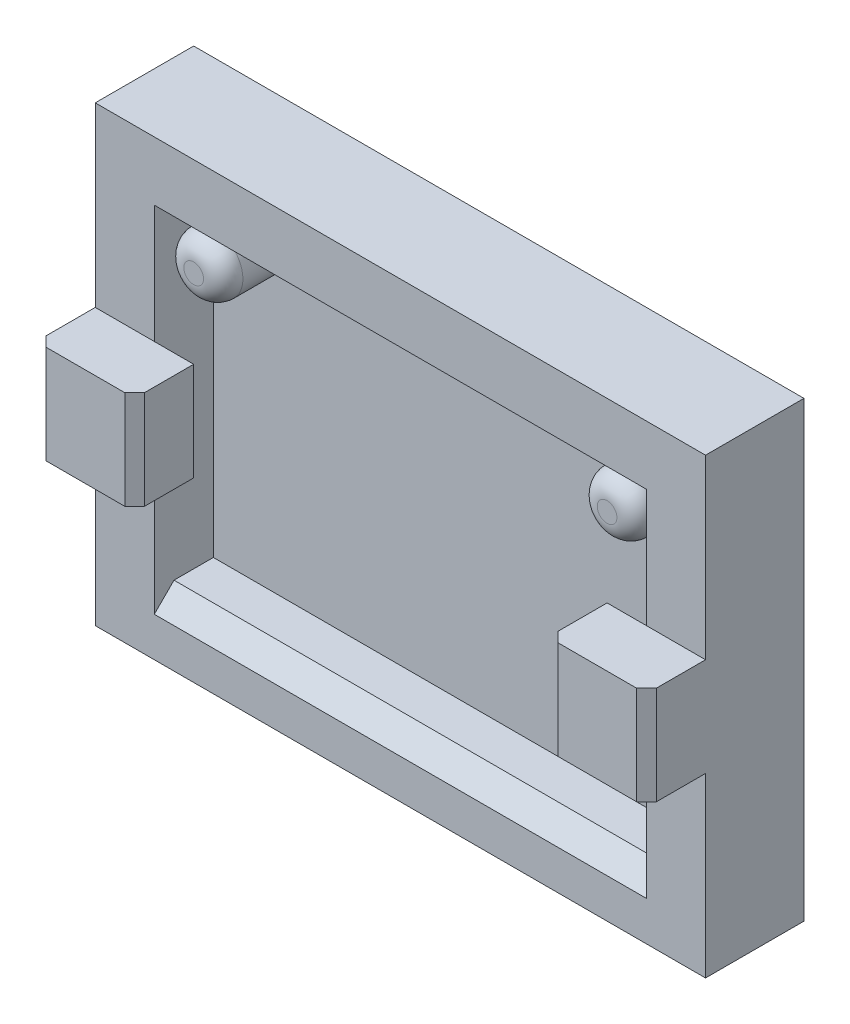
from build123d import *

# Parameters (mm, degrees)
ESQUISSE1_W             = 31
ESQUISSE1_H             = 23
BOSS_EXTRU_1_DEPTH      = 5
ESQUISSE2_W             = 25
ESQUISSE2_H             = 17
ENL_V_MAT_EXTRU_1_DEPTH = 3
ESQUISSE3_R             = 1.5
BOSS_EXTRU_2_DEPTH      = 3
CONG_1_R                = 1
ESQUISSE4_W             = 5
ESQUISSE4_H             = 5
BOSS_EXTRU_3_DEPTH      = 3
CHANFREIN1_SIZE         = 0.5
CHANFREIN2_SIZE         = 1


with BuildPart() as part:
    # Esquisse1 → Boss.-Extru.1 (new body)
    with BuildSketch(Plane.XY):
        with Locations((-15.5, 11.5)):
            Rectangle(ESQUISSE1_W, ESQUISSE1_H)
    extrude(amount=BOSS_EXTRU_1_DEPTH)

    # Esquisse2 → Enlèv. mat.-Extru.1 (cut)
    with BuildSketch(Plane.XY.offset(5)):
        with Locations((-15.5, 11.5)):
            Rectangle(ESQUISSE2_W, ESQUISSE2_H)
    extrude(amount=-ENL_V_MAT_EXTRU_1_DEPTH, mode=Mode.SUBTRACT)

    # Esquisse3 → Boss.-Extru.2 (add)
    with BuildSketch(Plane.XY.offset(2)):
        with Locations((-26, 18)):
            Circle(ESQUISSE3_R)
        with Locations((-5, 18)):
            Circle(ESQUISSE3_R)
    extrude(amount=BOSS_EXTRU_2_DEPTH)

    # Congé1
    cong_1_edges = [part.edges().sort_by_distance(p)[0] for p in [
        (-27.5, 18, 5),
        (-6.5, 18, 5),
    ]]
    fillet(cong_1_edges, radius=CONG_1_R)

    # Esquisse4 → Boss.-Extru.3 (add)
    with BuildSketch(Plane.XY.offset(5)):
        with Locations((-28.5, 11.5)):
            Rectangle(ESQUISSE4_W, ESQUISSE4_H)
        with Locations((-2.5, 11.5)):
            Rectangle(ESQUISSE4_W, ESQUISSE4_H)
    extrude(amount=BOSS_EXTRU_3_DEPTH)

    # Chanfrein1
    chanfrein1_edges = [part.edges().sort_by_distance(p)[0] for p in [
        (0, 11.5, 8),
        (-5, 11.5, 8),
        (-26, 11.5, 8),
        (-31, 11.5, 8),
    ]]
    chamfer(chanfrein1_edges, length=CHANFREIN1_SIZE)

    # Chanfrein2
    chanfrein2_edges = [part.edges().sort_by_distance(p)[0] for p in [
        (-15.5, 3, 5),
    ]]
    chamfer(chanfrein2_edges, length=CHANFREIN2_SIZE)


solid = part.part
